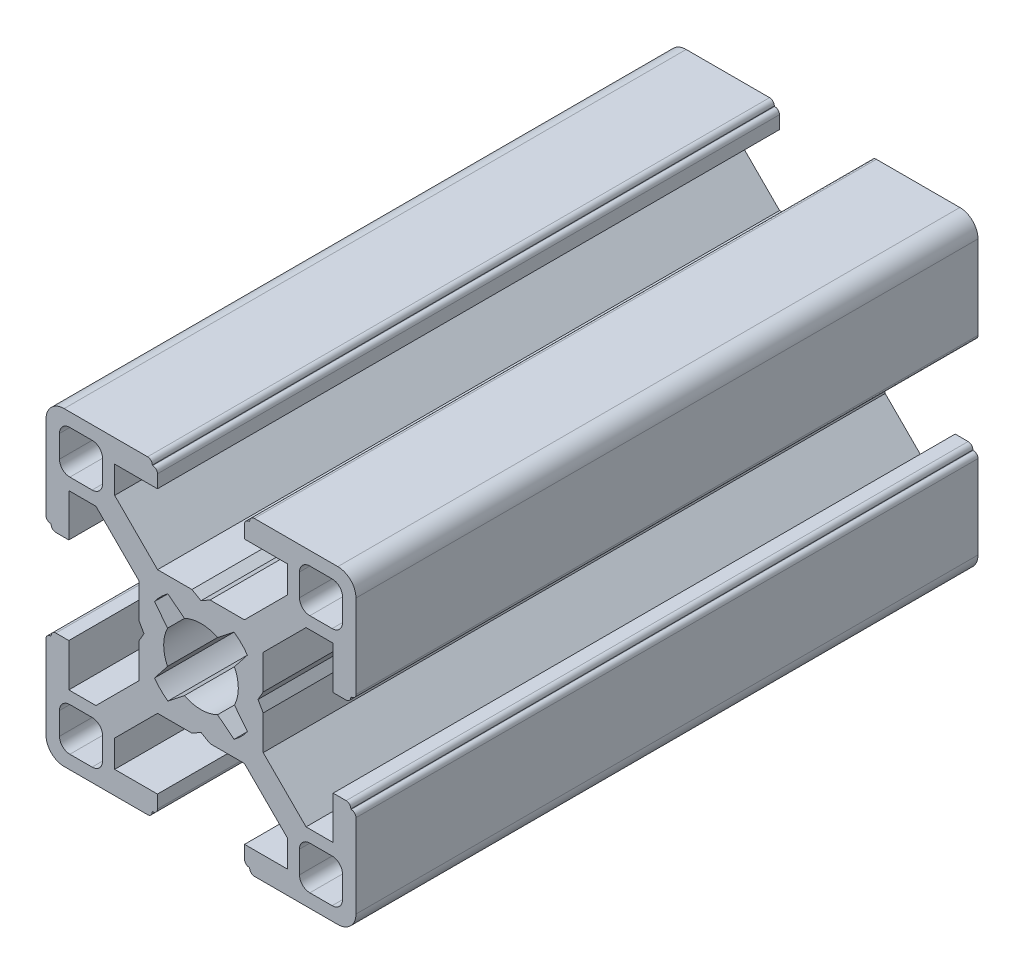
from build123d import *

# Parameters (mm, degrees)
BOSS_EXTRUDE1_DEPTH = 30


with BuildPart() as part:
    # Sketch1 → Boss-Extrude1 (new body, symmetric)
    with BuildSketch(Plane.XY):
        with BuildLine():
            Line((-8.325, 12.75), (-4.2, 12.75))
            Line((-4.2, 12.75), (-4.2, 14))
            ThreePointArc((-4.2, 14), (-4.331801948, 14.318198052), (-4.65, 14.45))
            Line((-4.65, 14.45), (-4.7, 14.45))
            Line((-4.7, 14.45), (-4.7, 14.5))
            ThreePointArc((-4.7, 14.5), (-4.831801948, 14.818198052), (-5.15, 14.95))
            Line((-5.15, 14.95), (-13.2, 14.95))
            ThreePointArc((-13.2, 14.95), (-14.437436867, 14.437436867), (-14.95, 13.2))
            Line((-14.95, 13.2), (-14.95, 5.15))
            ThreePointArc((-14.95, 5.15), (-14.818198052, 4.831801948), (-14.5, 4.7))
            Line((-14.5, 4.7), (-14.45, 4.7))
            Line((-14.45, 4.7), (-14.45, 4.65))
            ThreePointArc((-14.45, 4.65), (-14.318198052, 4.331801948), (-14, 4.2))
            Line((-14, 4.2), (-12.75, 4.2))
            Line((-12.75, 4.2), (-12.75, 8.325))
            Line((-12.75, 8.325), (-10.13519336, 8.325))
            Line((-10.13519336, 8.325), (-6, 4.18980664))
            Line((-6, 4.18980664), (-6, 0.875))
            Line((-6, 0.875), (-5.5, 0))
            Line((-5.5, 0), (-6, -0.875))
            Line((-6, -0.875), (-6, -4.18980664))
            Line((-6, -4.18980664), (-10.13519336, -8.325))
            Line((-10.13519336, -8.325), (-12.75, -8.325))
            Line((-12.75, -8.325), (-12.75, -4.2))
            Line((-12.75, -4.2), (-14, -4.2))
            ThreePointArc((-14, -4.2), (-14.318198052, -4.331801948), (-14.45, -4.65))
            Line((-14.45, -4.65), (-14.45, -4.7))
            Line((-14.45, -4.7), (-14.5, -4.7))
            ThreePointArc((-14.5, -4.7), (-14.818198052, -4.831801948), (-14.95, -5.15))
            Line((-14.95, -5.15), (-14.95, -13.2))
            ThreePointArc((-14.95, -13.2), (-14.437436867, -14.437436867), (-13.2, -14.95))
            Line((-13.2, -14.95), (-5.15, -14.95))
            ThreePointArc((-5.15, -14.95), (-4.831801948, -14.818198052), (-4.7, -14.5))
            Line((-4.7, -14.5), (-4.7, -14.45))
            Line((-4.7, -14.45), (-4.65, -14.45))
            ThreePointArc((-4.65, -14.45), (-4.331801948, -14.318198052), (-4.2, -14))
            Line((-4.2, -14), (-4.2, -12.75))
            Line((-4.2, -12.75), (-8.325, -12.75))
            Line((-8.325, -12.75), (-8.325, -10.13519336))
            Line((-8.325, -10.13519336), (-4.18980664, -6))
            Line((-4.18980664, -6), (-0.875, -6))
            Line((-0.875, -6), (0, -5.5))
            Line((0, -5.5), (0.875, -6))
            Line((0.875, -6), (4.18980664, -6))
            Line((4.18980664, -6), (8.325, -10.13519336))
            Line((8.325, -10.13519336), (8.325, -12.75))
            Line((8.325, -12.75), (4.2, -12.75))
            Line((4.2, -12.75), (4.2, -14))
            ThreePointArc((4.2, -14), (4.331801948, -14.318198052), (4.65, -14.45))
            Line((4.65, -14.45), (4.7, -14.45))
            Line((4.7, -14.45), (4.7, -14.5))
            ThreePointArc((4.7, -14.5), (4.831801948, -14.818198052), (5.15, -14.95))
            Line((5.15, -14.95), (13.2, -14.95))
            ThreePointArc((13.2, -14.95), (14.437436867, -14.437436867), (14.95, -13.2))
            Line((14.95, -13.2), (14.95, -5.15))
            ThreePointArc((14.95, -5.15), (14.818198052, -4.831801948), (14.5, -4.7))
            Line((14.5, -4.7), (14.45, -4.7))
            Line((14.45, -4.7), (14.45, -4.65))
            ThreePointArc((14.45, -4.65), (14.318198052, -4.331801948), (14, -4.2))
            Line((14, -4.2), (12.75, -4.2))
            Line((12.75, -4.2), (12.75, -8.325))
            Line((12.75, -8.325), (10.13519336, -8.325))
            Line((10.13519336, -8.325), (6, -4.18980664))
            Line((6, -4.18980664), (6, -0.875))
            Line((6, -0.875), (5.5, 0))
            Line((5.5, 0), (6, 0.875))
            Line((6, 0.875), (6, 4.18980664))
            Line((6, 4.18980664), (10.134787333, 8.324593973))
            Line((10.134787333, 8.324593973), (12.75, 8.324593973))
            Line((12.75, 8.324593973), (12.75, 4.2))
            Line((12.75, 4.2), (14, 4.2))
            ThreePointArc((14, 4.2), (14.318198052, 4.331801948), (14.45, 4.65))
            Line((14.45, 4.65), (14.45, 4.7))
            Line((14.45, 4.7), (14.5, 4.7))
            ThreePointArc((14.5, 4.7), (14.818198052, 4.831801948), (14.95, 5.15))
            Line((14.95, 5.15), (14.95, 13.2))
            ThreePointArc((14.95, 13.2), (14.437436867, 14.437436867), (13.2, 14.95))
            Line((13.2, 14.95), (5.15, 14.95))
            ThreePointArc((5.15, 14.95), (4.831801948, 14.818198052), (4.7, 14.5))
            Line((4.7, 14.5), (4.7, 14.45))
            Line((4.7, 14.45), (4.65, 14.45))
            ThreePointArc((4.65, 14.45), (4.331801948, 14.318198052), (4.2, 14))
            Line((4.2, 14), (4.2, 12.75))
            Line((4.2, 12.75), (8.324593973, 12.75))
            Line((8.324593973, 12.75), (8.324593973, 10.134787333))
            Line((8.324593973, 10.134787333), (4.18980664, 6))
            Line((4.18980664, 6), (0.875, 6))
            Line((0.875, 6), (0, 5.5))
            Line((0, 5.5), (-0.875, 6))
            Line((-0.875, 6), (-4.18980664, 6))
            Line((-4.18980664, 6), (-8.325, 10.13519336))
            Line((-8.325, 10.13519336), (-8.325, 12.75))
        make_face()
        with BuildLine():
            Line((-4.478803313, -3.194699355), (-3.226318161, -1.597144679))
            ThreePointArc((-3.226318161, -1.597144679), (-3.6, 0), (-3.226318161, 1.597144679))
            Line((-3.226318161, 1.597144679), (-4.478803313, 3.194699355))
            ThreePointArc((-4.478803313, 3.194699355), (-3.890101739, 3.890101739), (-3.194699355, 4.478803313))
            Line((-3.194699355, 4.478803313), (-1.597144679, 3.226318161))
            ThreePointArc((-1.597144679, 3.226318161), (0, 3.6), (1.597144679, 3.226318161))
            Line((1.597144679, 3.226318161), (3.194699355, 4.478803313))
            ThreePointArc((3.194699355, 4.478803313), (3.890101739, 3.890101739), (4.478803313, 3.194699355))
            Line((4.478803313, 3.194699355), (3.226318161, 1.597144679))
            ThreePointArc((3.226318161, 1.597144679), (3.6, 0), (3.226318161, -1.597144679))
            Line((3.226318161, -1.597144679), (4.478803313, -3.194699355))
            ThreePointArc((4.478803313, -3.194699355), (3.890101739, -3.890101739), (3.194699355, -4.478803313))
            Line((3.194699355, -4.478803313), (1.597144679, -3.226318161))
            ThreePointArc((1.597144679, -3.226318161), (0, -3.6), (-1.597144679, -3.226318161))
            Line((-1.597144679, -3.226318161), (-3.194699355, -4.478803313))
            ThreePointArc((-3.194699355, -4.478803313), (-3.890101739, -3.890101739), (-4.478803313, -3.194699355))
        make_face(mode=Mode.SUBTRACT)
        with BuildLine():
            Line((-13.65, -12.65), (-13.65, -10.5))
            ThreePointArc((-13.65, -10.5), (-13.357106781, -9.792893219), (-12.65, -9.5))
            Line((-12.65, -9.5), (-10.5, -9.5))
            ThreePointArc((-10.5, -9.5), (-9.792893219, -9.792893219), (-9.5, -10.5))
            Line((-9.5, -10.5), (-9.5, -12.65))
            ThreePointArc((-9.5, -12.65), (-9.792893219, -13.357106781), (-10.5, -13.65))
            Line((-10.5, -13.65), (-12.65, -13.65))
            ThreePointArc((-12.65, -13.65), (-13.357106781, -13.357106781), (-13.65, -12.65))
        make_face(mode=Mode.SUBTRACT)
        with BuildLine():
            Line((9.5, 10.5), (9.5, 12.65))
            ThreePointArc((9.5, 12.65), (9.792893219, 13.357106781), (10.5, 13.65))
            Line((10.5, 13.65), (12.65, 13.65))
            ThreePointArc((12.65, 13.65), (13.357106781, 13.357106781), (13.65, 12.65))
            Line((13.65, 12.65), (13.65, 10.5))
            ThreePointArc((13.65, 10.5), (13.357106781, 9.792893219), (12.65, 9.5))
            Line((12.65, 9.5), (10.5, 9.5))
            ThreePointArc((10.5, 9.5), (9.792893219, 9.792893219), (9.5, 10.5))
        make_face(mode=Mode.SUBTRACT)
        with BuildLine():
            Line((-13.65, 10.5), (-13.65, 12.65))
            ThreePointArc((-13.65, 12.65), (-13.357106781, 13.357106781), (-12.65, 13.65))
            Line((-12.65, 13.65), (-10.5, 13.65))
            ThreePointArc((-10.5, 13.65), (-9.792893219, 13.357106781), (-9.5, 12.65))
            Line((-9.5, 12.65), (-9.5, 10.5))
            ThreePointArc((-9.5, 10.5), (-9.792893219, 9.792893219), (-10.5, 9.5))
            Line((-10.5, 9.5), (-12.65, 9.5))
            ThreePointArc((-12.65, 9.5), (-13.357106781, 9.792893219), (-13.65, 10.5))
        make_face(mode=Mode.SUBTRACT)
        with BuildLine():
            Line((10.5, -9.5), (12.65, -9.5))
            ThreePointArc((12.65, -9.5), (13.357106781, -9.792893219), (13.65, -10.5))
            Line((13.65, -10.5), (13.65, -12.65))
            ThreePointArc((13.65, -12.65), (13.357106781, -13.357106781), (12.65, -13.65))
            Line((12.65, -13.65), (10.5, -13.65))
            ThreePointArc((10.5, -13.65), (9.792893219, -13.357106781), (9.5, -12.65))
            Line((9.5, -12.65), (9.5, -10.5))
            ThreePointArc((9.5, -10.5), (9.792893219, -9.792893219), (10.5, -9.5))
        make_face(mode=Mode.SUBTRACT)
    extrude(amount=BOSS_EXTRUDE1_DEPTH, both=True)


solid = part.part
